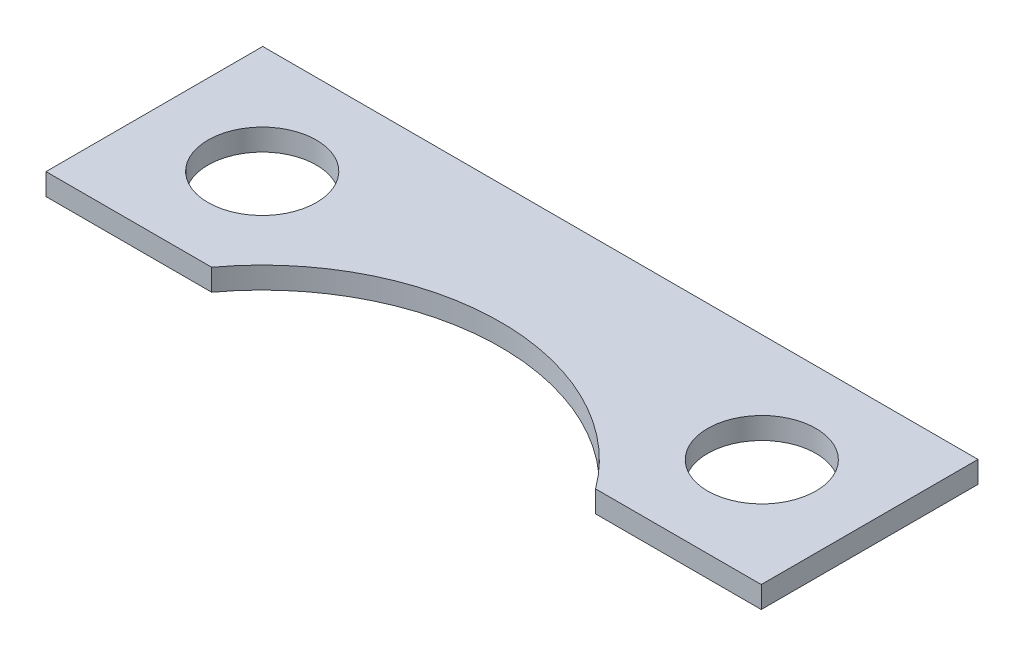
from build123d import *

# Parameters (mm, degrees)
SKETCH1_R           = 2.5
BOSS_EXTRUDE1_DEPTH = 1


with BuildPart() as part:
    # Sketch1 → Boss-Extrude1 (new body)
    with BuildSketch(Plane(origin=(0, 0, 0), x_dir=(1, 0, 0), z_dir=(0, 1, 0))):
        with BuildLine():
            Line((-16.5, 10), (16.5, 10))
            Line((16.5, 10), (16.5, 0))
            Line((16.5, 0), (8.855753779, 0))
            ThreePointArc((8.855753779, 0), (0, 4.475), (-8.855753779, 0))
            Line((-8.855753779, 0), (-16.5, 0))
            Line((-16.5, 0), (-16.5, 10))
        make_face()
        with Locations((-11.525, 5)):
            Circle(SKETCH1_R, mode=Mode.SUBTRACT)
        with Locations((11.525, 5)):
            Circle(SKETCH1_R, mode=Mode.SUBTRACT)
    extrude(amount=BOSS_EXTRUDE1_DEPTH)


solid = part.part
